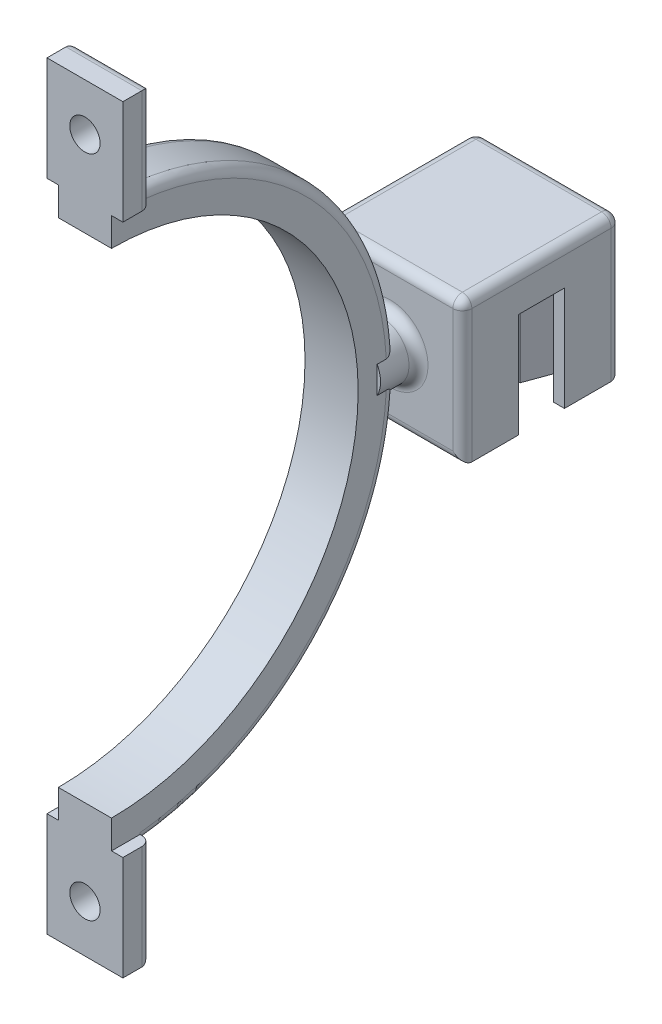
from build123d import *

# Parameters (mm, degrees)
BOSS_EXTRUDE1_DEPTH   = 11
BOSS_EXTRUDE1_2_DEPTH = 11
SKETCH2_W             = 15.446473034
SKETCH2_H             = 16.677637278
BOSS_EXTRUDE2_DEPTH   = 4
SKETCH3_R             = 3
BOSS_EXTRUDE3_DEPTH   = 4
BOSS_EXTRUDE4_DEPTH   = 2.8
CUT_EXTRUDE1_DEPTH    = 11
SKETCH11_W            = 0.1
SKETCH11_H            = 16.677637278
CUT_EXTRUDE2_DEPTH    = 11
SKETCH12_W            = 8
SKETCH12_H            = 14
SKETCH12_R            = 1.6
BOSS_EXTRUDE5_DEPTH   = 3
FILLET1_R             = 1
SKETCH14_W            = 1.465452289
SKETCH14_H            = 3.319739537
SKETCH14_W_2          = 1.579669893
CUT_EXTRUDE3_DEPTH    = 3
SKETCH15_W            = 1.507141025
SKETCH15_H            = 3.716681852
SKETCH15_W_2          = 1.554838049
SKETCH15_H_2          = 3.443775751
CUT_EXTRUDE4_DEPTH    = 3


with BuildPart() as part:
    # Sketch1 → Boss-Extrude1 (new body)
    with BuildSketch(Plane(origin=(0, 0, 0), x_dir=(1, 0, 0), z_dir=(0, 1, 0))):
        Polygon((6.574205289, -3.388868816), (7.883511398, -3.388868816), (7.883511398, -9.402687455), (-7.562961636, -9.402687455), (-7.562961636, -3.388868816), (-6.253655527, -3.388868816), (-5.025255986, -6.763868816), (-4.078972201, -6.763868816), (-2.850572661, -3.388868816), (-1.541266552, -3.388868816), (-0.312867011, -6.763868816), (0.633416774, -6.763868816), (1.861816314, -3.388868816), (3.171122423, -3.388868816), (4.399521964, -6.763868816), (5.345805749, -6.763868816), align=None)
    extrude(amount=BOSS_EXTRUDE1_DEPTH)



with BuildPart() as body_2:
    # Sketch1 → Boss-Extrude1 2 (new body)
    with BuildSketch(Plane(origin=(0, 0, 0), x_dir=(1, 0, 0), z_dir=(0, 1, 0))):
        Polygon((6.574205289, 1.261131184), (7.883511398, 1.261131184), (7.883511398, 7.274949823), (-7.562961636, 7.274949823), (-7.562961636, 1.261131184), (-6.253655527, 1.261131184), (-5.025255986, 4.636131184), (-4.078972201, 4.636131184), (-2.850572661, 1.261131184), (-1.541266552, 1.261131184), (-0.312867011, 4.636131184), (0.633416774, 4.636131184), (1.861816314, 1.261131184), (3.171122423, 1.261131184), (4.399521964, 4.636131184), (5.345805749, 4.636131184), align=None)
    extrude(amount=BOSS_EXTRUDE1_2_DEPTH)


with BuildPart() as part_1:
    add(part.part)

    add(body_2.part)  # Boss-Extrude2 merges body 2
    # Sketch2 → Boss-Extrude2 (add)
    with BuildSketch(Plane(origin=(0, 11, 0), x_dir=(1, 0, 0), z_dir=(0, 1, 0))):
        with Locations((0.160274881, -1.063868816)):
            Rectangle(SKETCH2_W, SKETCH2_H)
    extrude(amount=BOSS_EXTRUDE2_DEPTH)

    # Sketch3 → Boss-Extrude3 (add)
    with BuildSketch(Plane.XY.offset(9.402687455)):
        with Locations((0.160274881, 7.5)):
            Circle(SKETCH3_R)
    extrude(amount=BOSS_EXTRUDE3_DEPTH)

    # Sketch7 → Boss-Extrude4 (add, symmetric)
    with BuildSketch(Plane(origin=(0, 0, 0), x_dir=(0, 0, -1), z_dir=(1, 0, 0))):
        with BuildLine():
            Line((-41.402687455, -22.5), (-41.402687455, -18.5))
            ThreePointArc((-41.402687455, -18.5), (-15.402687455, 7.5), (-41.402687455, 33.5))
            Line((-41.402687455, 33.5), (-41.402687455, 37.5))
            ThreePointArc((-41.402687455, 37.5), (-11.402687455, 7.5), (-41.402687455, -22.5))
        make_face()
    extrude(amount=BOSS_EXTRUDE4_DEPTH, both=True)

    # Sketch9 → Cut-Extrude1 (cut)
    with BuildSketch(Plane(origin=(0, 0, 0), x_dir=(-1, 0, 0), z_dir=(0, -1, 0))):
        Polygon((7.462961636, -9.402687455), (7.462961636, -3.488868816), (6.323676281, -3.488868816), (5.09527674, -6.863868816), (4.008951448, -6.863868816), (2.780551907, -3.488868816), (1.611287306, -3.488868816), (0.382887765, -6.863868816), (-0.703437527, -6.863868816), (-1.931837068, -3.488868816), (-3.101101669, -3.488868816), (-4.32950121, -6.863868816), (-5.415826502, -6.863868816), (-6.644226043, -3.488868816), (-7.783511398, -3.488868816), (-7.783511398, -9.402687455), (-7.883511398, -9.402687455), (-7.883511398, -3.388868816), (-6.574205289, -3.388868816), (-5.345805749, -6.763868816), (-4.399521964, -6.763868816), (-3.171122423, -3.388868816), (-1.861816314, -3.388868816), (-0.633416774, -6.763868816), (0.312867011, -6.763868816), (1.541266552, -3.388868816), (2.850572661, -3.388868816), (4.078972201, -6.763868816), (5.025255986, -6.763868816), (6.253655527, -3.388868816), (7.562961636, -3.388868816), (7.562961636, -9.402687455), align=None)
        Polygon((7.562961636, 1.261131184), (7.562961636, 7.274949823), (7.462961636, 7.274949823), (7.462961636, 1.361131184), (6.323676281, 1.361131184), (5.09527674, 4.736131184), (4.008951448, 4.736131184), (2.780551907, 1.361131184), (1.611287306, 1.361131184), (0.382887765, 4.736131184), (-0.703437527, 4.736131184), (-1.931837068, 1.361131184), (-3.101101669, 1.361131184), (-4.32950121, 4.736131184), (-5.415826502, 4.736131184), (-6.644226043, 1.361131184), (-7.783511398, 1.361131184), (-7.783511398, 7.274949823), (-7.883511398, 7.274949823), (-7.883511398, 1.261131184), (-6.574205289, 1.261131184), (-5.345805749, 4.636131184), (-4.399521964, 4.636131184), (-3.171122423, 1.261131184), (-1.861816314, 1.261131184), (-0.633416774, 4.636131184), (0.312867011, 4.636131184), (1.541266552, 1.261131184), (2.850572661, 1.261131184), (4.078972201, 4.636131184), (5.025255986, 4.636131184), (6.253655527, 1.261131184), align=None)
    extrude(amount=-CUT_EXTRUDE1_DEPTH, mode=Mode.SUBTRACT)

    # Sketch11 → Cut-Extrude2 (cut)
    with BuildSketch(Plane.XZ.offset(-11)):
        with Locations((7.833511398, 1.063868816)):
            Rectangle(SKETCH11_W, SKETCH11_H)
        with Locations((-7.512961636, 1.063868816)):
            Rectangle(SKETCH11_W, SKETCH11_H)
    extrude(amount=-CUT_EXTRUDE2_DEPTH, mode=Mode.SUBTRACT)

    # Sketch12 → Boss-Extrude5 (add)
    with BuildSketch(Plane.XY.offset(41.402687455)):
        with Locations((0, -25.5)):
            Rectangle(SKETCH12_W, SKETCH12_H)
        with Locations((0, -27.5)):
            Circle(SKETCH12_R, mode=Mode.SUBTRACT)
    boss_extrude5 = extrude(amount=-BOSS_EXTRUDE5_DEPTH)

    # Mirror1: Boss-Extrude5 across plane
    add(boss_extrude5.mirror(Plane.ZX.offset(7.5)))

    # Fillet1
    fillet1_edges = [part_1.edges().sort_by_distance(p)[0] for p in [
        (0.160274881, 0, 9.402687455),
        (-7.462961636, 7.5, 9.402687455),
        (7.783511398, 7.5, 9.402687455),
        (-2.839725119, 7.5, 9.402687455),
        (-7.462961636, 7.5, -7.274949823),
        (0.160274881, 0, -7.274949823),
        (7.783511398, 7.5, -7.274949823),
        (0.160274881, 15, 9.402687455),
        (-7.462961636, 15, 1.063868816),
        (0.160274881, 15, -7.274949823),
        (7.783511398, 15, 1.063868816),
        (0, -32.5, 38.402687455),
        (-4, -25.5, 38.402687455),
        (4, -25.5, 38.402687455),
        (0, 47.5, 38.402687455),
        (4, 40.5, 38.402687455),
        (-4, 40.5, 38.402687455),
        (-2.8, 27.804389345, 19.318037281),
        (2.8, 28.147641568, 19.638613901),
        (-2.8, -12.804389345, 19.318037281),
        (2.8, -13.147641568, 19.638613901),
    ]]
    fillet(fillet1_edges, radius=FILLET1_R)

    # Sketch14 → Cut-Extrude3 (cut)
    with BuildSketch(Plane.XZ.offset(-33.5)):
        with Locations((-3.532726145, 39.742817687)):
            Rectangle(SKETCH14_W, SKETCH14_H)
        with Locations((3.589834946, 39.742817687)):
            Rectangle(SKETCH14_W_2, SKETCH14_H)
    extrude(amount=-CUT_EXTRUDE3_DEPTH, mode=Mode.SUBTRACT)

    # Sketch15 → Cut-Extrude4 (cut)
    with BuildSketch(Plane(origin=(0, -18.5, 0), x_dir=(1, 0, 0), z_dir=(0, 1, 0))):
        with Locations((3.553570513, -39.544346529)):
            Rectangle(SKETCH15_W, SKETCH15_H)
        with Locations((-3.577419025, -39.68079958)):
            Rectangle(SKETCH15_W_2, SKETCH15_H_2)
    extrude(amount=-CUT_EXTRUDE4_DEPTH, mode=Mode.SUBTRACT)


solid = part_1.part
